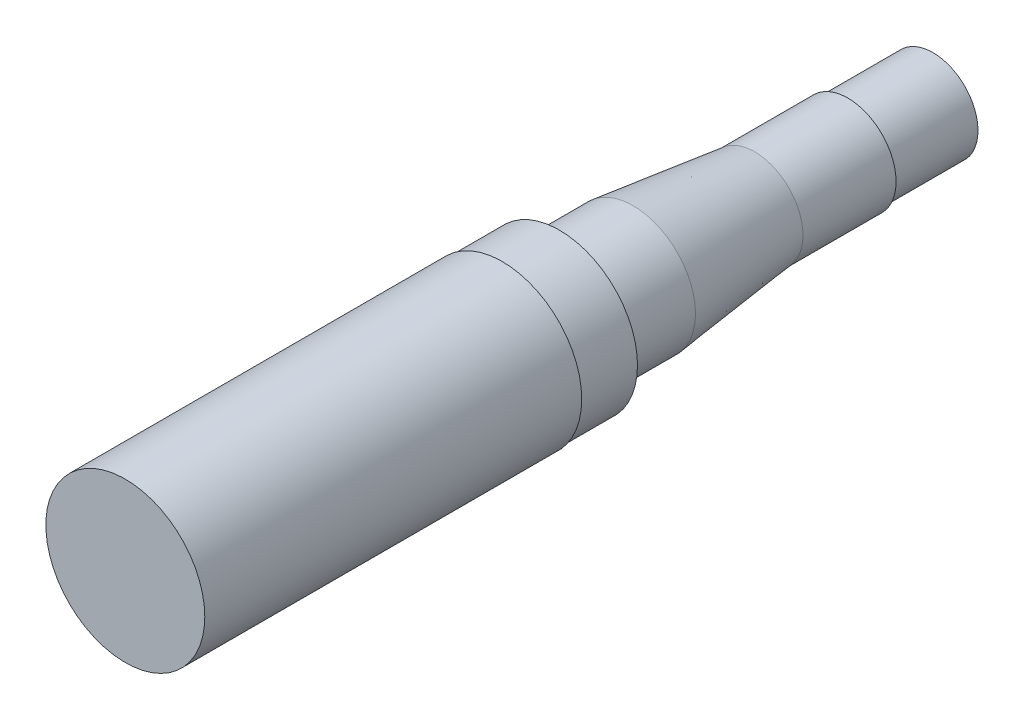
from build123d import *


with BuildPart() as part:
    # Sketch1 → Revolve1 (revolve)
    with BuildSketch(Plane(origin=(0, 0, 0), x_dir=(0, 0, -1), z_dir=(1, 0, 0)), mode=Mode.PRIVATE) as revolve1_sk:
        with BuildLine():
            Line((0, 0), (0, 22.225))
            Line((0, 22.225), (105.41, 22.225))
            Line((105.41, 22.225), (105.41, 21.8186))
            Line((105.41, 21.8186), (121.412, 21.8186))
            Line((121.412, 21.8186), (121.412, 19.3675))
            ThreePointArc((121.412, 19.3675), (121.969961582, 18.020461582), (123.317, 17.4625))
            Line((123.317, 17.4625), (141.986, 17.4625))
            Line((141.986, 17.4625), (176.022, 13.4874))
            Line((176.022, 13.4874), (202.057, 13.4874))
            Line((202.057, 13.4874), (202.057, 13.2334))
            ThreePointArc((202.057, 13.2334), (202.242987194, 12.784387194), (202.692, 12.5984))
            Line((202.692, 12.5984), (204.597, 12.5984))
            Line((204.597, 12.5984), (225.8568, 12.5984))
            Line((225.8568, 12.5984), (225.8568, 0))
            Line((225.8568, 0), (0, 0))
        make_face()
    revolve(revolve1_sk.sketch.rotate(Axis((0, 0, 0), (0, 0, -1)), 90), axis=Axis((0, 0, 0), (0, 0, -1)))


solid = part.part
